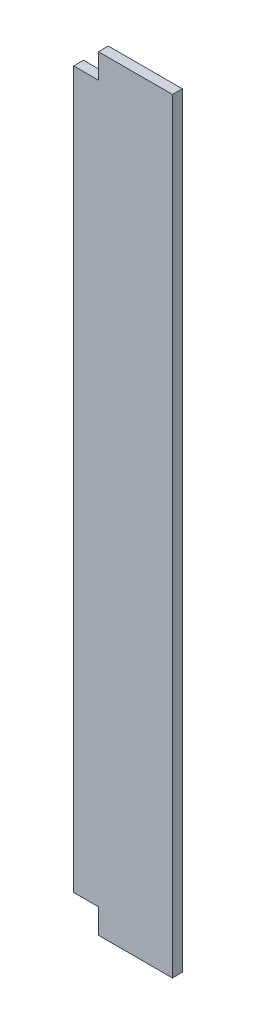
from build123d import *

# Parameters (mm, degrees)
ESBO_O1_W                = 200
ESBO_O1_H                = 20
RESSALTO_EXTRUS_O1_DEPTH = 1550
ESBO_O2_W                = 50
ESBO_O2_H                = 50
CORTE_EXTRUS_O1_DEPTH    = 21
ESBO_O3_W                = 50
ESBO_O3_H                = 50
CORTE_EXTRUS_O2_DEPTH    = 21


with BuildPart() as part:
    # Esboço1 → Ressalto-extrusão1 (new body)
    with BuildSketch(Plane(origin=(0, 0, 0), x_dir=(1, 0, 0), z_dir=(0, 1, 0))):
        with Locations((-29.608938547, 57.458100559)):
            Rectangle(ESBO_O1_W, ESBO_O1_H)
    extrude(amount=RESSALTO_EXTRUS_O1_DEPTH)

    # Esboço2 → Corte-extrusão1 (cut, through all)
    with BuildSketch(Plane.XY.offset(-47.458100559)):
        with Locations((-104.608938547, 25)):
            Rectangle(ESBO_O2_W, ESBO_O2_H)
    extrude(amount=-CORTE_EXTRUS_O1_DEPTH, mode=Mode.SUBTRACT)

    # Esboço3 → Corte-extrusão2 (cut, through all)
    with BuildSketch(Plane.XY.offset(-47.458100559)):
        with Locations((-104.608938547, 1525)):
            Rectangle(ESBO_O3_W, ESBO_O3_H)
    extrude(amount=-CORTE_EXTRUS_O2_DEPTH, mode=Mode.SUBTRACT)


solid = part.part
